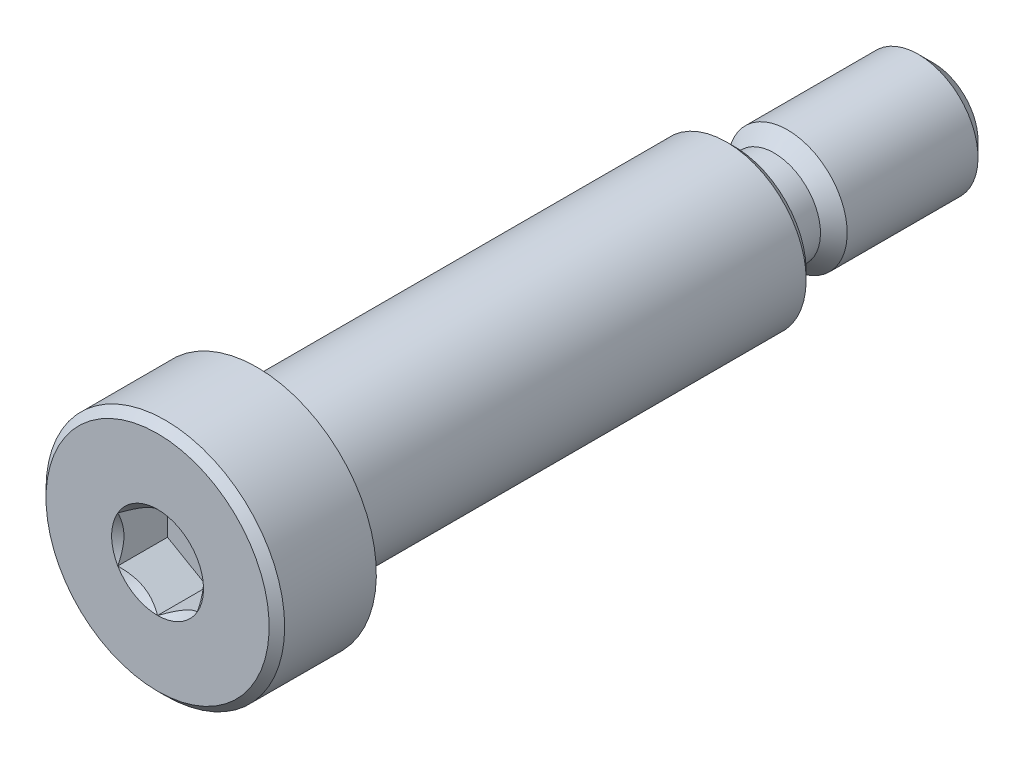
from build123d import *

# Parameters (mm, degrees)
CHAMFER1_SIZE      = 1.190625
CHAMFER2_SIZE      = 0.619125
CUT_EXTRUDE2_DEPTH = 3.96875


with BuildPart() as part:
    # Sketch1 → Revolve1 (revolve)
    with BuildSketch(Plane(origin=(0, 0, 0), x_dir=(0, 0, -1), z_dir=(1, 0, 0))):
        Polygon((0, 9.525), (7.9375, 9.525), (7.9375, 6.35), (46.0375, 6.35), (46.0375, 4.7625), (61.9125, 4.7625), (61.9125, 0), (0, 0), align=None)
    revolve(axis=Axis((0, 0, -61.9125), (0, 0, 1)))

    # Sketch5 → Cut-Revolve1 (revolve, cut)
    with BuildSketch(Plane(origin=(0, 0, 0), x_dir=(0, 0, -1), z_dir=(1, 0, 0))):
        with BuildLine():
            Line((46.0375, 6.35), (51.8668, 6.35))
            Line((51.8668, 6.35), (49.2125, 3.6957))
            Line((49.2125, 3.6957), (47.1043, 3.6957))
            ThreePointArc((47.1043, 3.6957), (46.349958486, 4.008158486), (46.0375, 4.7625))
            Line((46.0375, 4.7625), (46.0375, 6.35))
        make_face()
    revolve(axis=Axis((0, 0, -61.9125), (0, 0, 1)), mode=Mode.SUBTRACT)

    # Chamfer1
    chamfer1_edges = [part.edges().sort_by_distance(p)[0] for p in [
        (0, -4.7625, -61.9125),
    ]]
    chamfer(chamfer1_edges, length=CHAMFER1_SIZE)

    # Chamfer2
    chamfer2_edges = [part.edges().sort_by_distance(p)[0] for p in [
        (0, -9.525, 0),
        (0, -6.35, -46.0375),
    ]]
    chamfer(chamfer2_edges, length=CHAMFER2_SIZE)

    # Sketch8 → Cut-Extrude2 (cut)
    with BuildSketch(Plane.XY):
        Polygon((3.175, 1.833087105), (0, 3.666174209), (-3.175, 1.833087105), (-3.175, -1.833087105), (0, -3.666174209), (3.175, -1.833087105), align=None)
    extrude(amount=-CUT_EXTRUDE2_DEPTH, mode=Mode.SUBTRACT)

    # Cut-Extrude4 cone 1 section (through the dimple's axis) → Cut-Extrude4 (revolve, cut)
    with BuildSketch(Plane(origin=(0, 0, 0), x_dir=(0, -1, 0), z_dir=(1, 0, 0))):
        Polygon((0, 0), (3.666174209, 0), (0, 3.666174209), align=None)
    revolve(axis=Axis((0, 0, 0), (0, 0, -1)), mode=Mode.SUBTRACT)


solid = part.part
